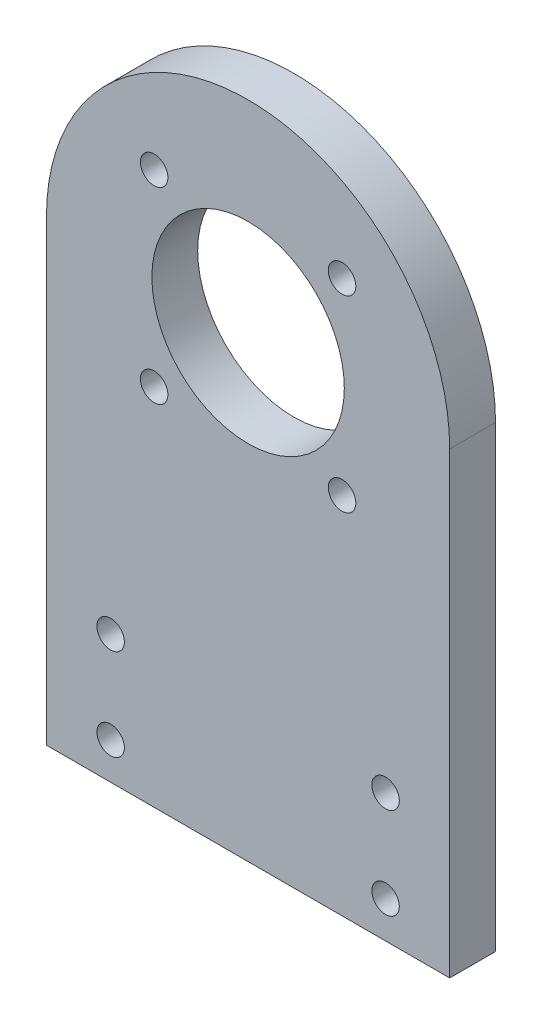
from build123d import *

# Parameters (mm, degrees)
SKETCH_1_R          = 1.5
SKETCH_1_R_2        = 10.5
EXTRUDE_1_DEPTH     = 5
SKETCH_2_R          = 1.5
CUT_EXTRUDE_1_DEPTH = 6


with BuildPart() as part:
    # 草图1 → 凸台-拉伸1 (new body)
    with BuildSketch(Plane.XY):
        with BuildLine():
            Line((-22, 0), (22, 0))
            Line((22, 0), (22, 50))
            ThreePointArc((22, 50), (0, 72), (-22, 50))
            Line((-22, 50), (-22, 0))
        make_face()
        with Locations((-15, 14)):
            Circle(SKETCH_1_R, mode=Mode.SUBTRACT)
        with Locations((-15, 4)):
            Circle(SKETCH_1_R, mode=Mode.SUBTRACT)
        with Locations((15, 4)):
            Circle(SKETCH_1_R, mode=Mode.SUBTRACT)
        with Locations((15, 14)):
            Circle(SKETCH_1_R, mode=Mode.SUBTRACT)
        with Locations((0, 50)):
            Circle(SKETCH_1_R_2, mode=Mode.SUBTRACT)
    extrude(amount=EXTRUDE_1_DEPTH)

    # 草图2 → 切除-拉伸1 (cut, through all)
    with BuildSketch(Plane(origin=(0, 0, 0), x_dir=(-1, 0, 0), z_dir=(0, 0, -1))):
        with Locations((10.253048327, 60.253048327)):
            Circle(SKETCH_2_R)
        with Locations((10.253048327, 39.746951673)):
            Circle(SKETCH_2_R)
        with Locations((-10.253048327, 39.746951673)):
            Circle(SKETCH_2_R)
        with Locations((-10.253048327, 60.253048327)):
            Circle(SKETCH_2_R)
    extrude(amount=-CUT_EXTRUDE_1_DEPTH, mode=Mode.SUBTRACT)


solid = part.part
